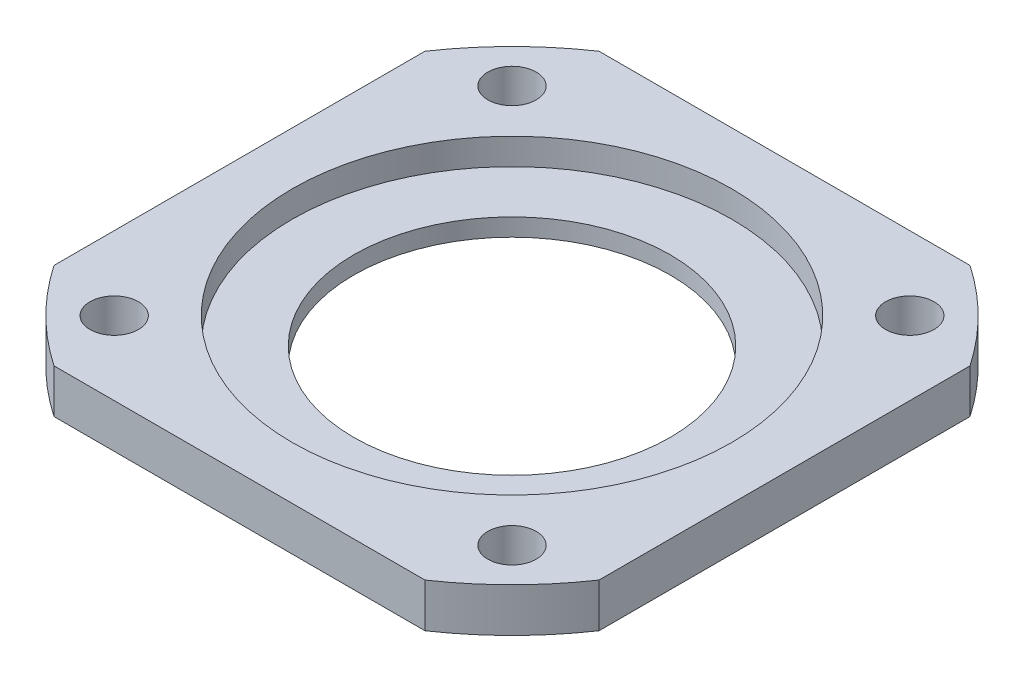
from build123d import *

# Parameters (mm, degrees)
SKETCH1_R           = 37.5
SKETCH1_R_2         = 18
BOSS_EXTRUDE1_DEPTH = 5
SKETCH2_R           = 25
CUT_EXTRUDE1_DEPTH  = 3
SKETCH3_OUTSIDE_W   = 98.236
SKETCH3_OUTSIDE_H   = 98.236
SKETCH3_OUTSIDE_W_2 = 62
SKETCH3_OUTSIDE_H_2 = 62
CUT_EXTRUDE2_DEPTH  = 6
SKETCH4_R           = 2.75
CUT_EXTRUDE3_DEPTH  = 6


with BuildPart() as part:
    # Sketch1 → Boss-Extrude1 (new body)
    with BuildSketch(Plane(origin=(0, 0, 0), x_dir=(1, 0, 0), z_dir=(0, 1, 0))):
        Circle(SKETCH1_R)
        Circle(SKETCH1_R_2, mode=Mode.SUBTRACT)
    extrude(amount=BOSS_EXTRUDE1_DEPTH)

    # Sketch2 → Cut-Extrude1 (cut)
    with BuildSketch(Plane(origin=(0, 5, 0), x_dir=(1, 0, 0), z_dir=(0, 1, 0))):
        Circle(SKETCH2_R)
    extrude(amount=-CUT_EXTRUDE1_DEPTH, mode=Mode.SUBTRACT)

    # Sketch3 outside → Cut-Extrude2 (cut, through all)
    with BuildSketch(Plane(origin=(0, 5, 0), x_dir=(1, 0, 0), z_dir=(0, 1, 0))):
        Rectangle(SKETCH3_OUTSIDE_W, SKETCH3_OUTSIDE_H)
        Rectangle(SKETCH3_OUTSIDE_W_2, SKETCH3_OUTSIDE_H_2, mode=Mode.SUBTRACT)
    extrude(amount=-CUT_EXTRUDE2_DEPTH, mode=Mode.SUBTRACT)

    # Sketch4 → Cut-Extrude3 (cut, through all)
    with BuildSketch(Plane(origin=(0, 5, 0), x_dir=(1, 0, 0), z_dir=(0, 1, 0))):
        with Locations((-22.627416998, 22.627416998)):
            Circle(SKETCH4_R)
        with Locations((22.627416998, 22.627416998)):
            Circle(SKETCH4_R)
        with Locations((22.627416998, -22.627416998)):
            Circle(SKETCH4_R)
        with Locations((-22.627416998, -22.627416998)):
            Circle(SKETCH4_R)
    extrude(amount=-CUT_EXTRUDE3_DEPTH, mode=Mode.SUBTRACT)


solid = part.part
